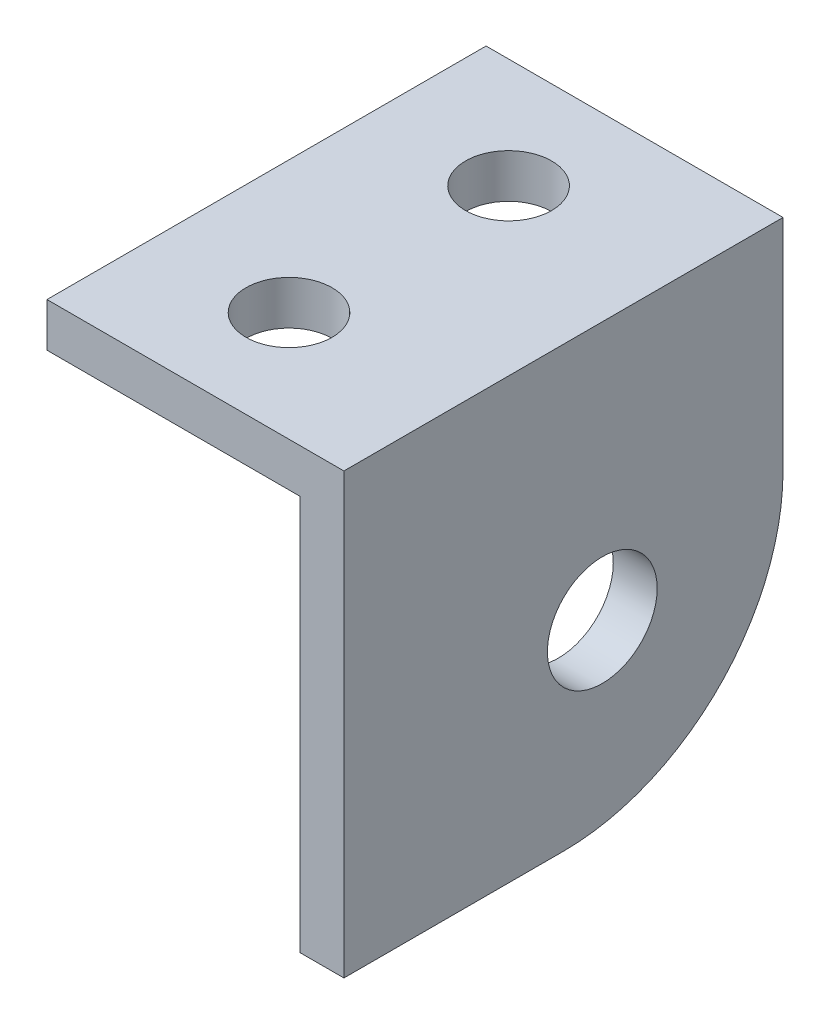
from build123d import *

# Parameters (mm, degrees)
BOSS_EXTRUDE1_DEPTH = 25.4
FILLET1_R           = 12.7
SKETCH2_R           = 3.175
CUT_EXTRUDE1_DEPTH  = 18.17675
SKETCH3_R           = 2.4892
CUT_EXTRUDE2_DEPTH  = 3.54


with BuildPart() as part:
    # Sketch1 → Boss-Extrude1 (new body)
    with BuildSketch(Plane.XY):
        Polygon((-10.16, -12.7), (-10.16, 12.7), (-27.33675, 12.7), (-27.33675, 10.16), (-12.7, 10.16), (-12.7, -12.7), align=None)
    extrude(amount=BOSS_EXTRUDE1_DEPTH)

    # Fillet1
    fillet1_edges = [part.edges().sort_by_distance(p)[0] for p in [
        (-11.43, -12.7, 0),
    ]]
    fillet(fillet1_edges, radius=FILLET1_R)

    # Sketch2 → Cut-Extrude1 (cut, through all)
    with BuildSketch(Plane(origin=(-10.16, 0, 0), x_dir=(0, 0, -1), z_dir=(1, 0, 0))):
        with Locations((-10.45493597, -2.24506403)):
            Circle(SKETCH2_R)
    extrude(amount=-CUT_EXTRUDE1_DEPTH, mode=Mode.SUBTRACT)

    # Sketch3 → Cut-Extrude2 (cut, through all)
    with BuildSketch(Plane(origin=(-0.012018133, 10.16, 0), x_dir=(1, 0, 0), z_dir=(0, -1, 0))):
        with Locations((-19.672981867, 19.05)):
            Circle(SKETCH3_R)
        with Locations((-19.672981867, 6.35)):
            Circle(SKETCH3_R)
    extrude(amount=-CUT_EXTRUDE2_DEPTH, mode=Mode.SUBTRACT)


solid = part.part
